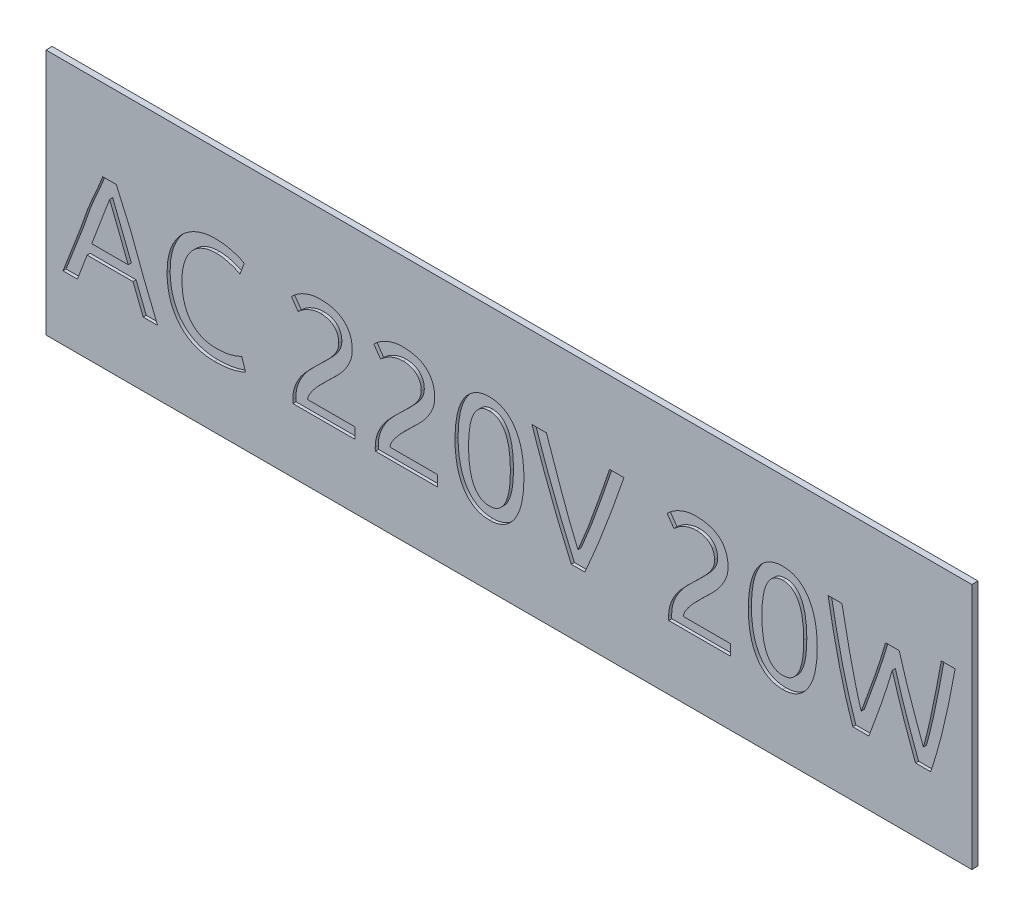
from build123d import *

# Parameters (mm, degrees)
SKETCH1_W           = 30
SKETCH1_H           = 8
BOSS_EXTRUDE1_DEPTH = 0.1
CUT_EXTRUDE1_DEPTH  = 0.1


with BuildPart() as part:
    # Sketch1 → Boss-Extrude1 (new body, symmetric)
    with BuildSketch(Plane.XY):
        Rectangle(SKETCH1_W, SKETCH1_H)
    extrude(amount=BOSS_EXTRUDE1_DEPTH, both=True)

    # Sketch2 → Cut-Extrude1 (cut)
    with BuildSketch(Plane.XY.offset(0.1)):
        with BuildLine():
            add(Edge.make_bspline(
                [(-11.85227279, -1.921252175), (-11.881209248, -1.84755212), (-11.937394401, -1.704450679), (-12.020606646, -1.494273216), (-12.10054261, -1.290409407), (-12.153603578, -1.156094189), (-12.180095068, -1.089035286)],
                knots=[0, 0, 0, 0, 0.000237531, 0.000461208, 0.000678151, 0.000894457, 0.000894457, 0.000894457, 0.000894457], degree=3))
            Line((-12.180095068, -1.089035286), (-13.667272123, -1.089035286))
            Line((-13.667272123, -1.089035286), (-13.981406623, -1.921252175))
            Line((-13.981406623, -1.921252175), (-14.449528623, -1.921252175))
            add(Edge.make_bspline(
                [(-14.449528623, -1.921252175), (-14.416767966, -1.837265115), (-14.35237101, -1.672173463), (-14.256095149, -1.429893418), (-14.165566046, -1.195825565), (-14.076612758, -0.971104345), (-13.991538842, -0.752741226), (-13.91301338, -0.538795074), (-13.836511428, -0.329944019), (-13.768048446, -0.12398361), (-13.698874096, 0.076744701), (-13.625453333, 0.271113549), (-13.54914922, 0.459554102), (-13.441064158, 0.701726294), (-13.306538256, 1.000464068), (-13.209270592, 1.243009526), (-13.160824345, 1.363814492)],
                knots=[0, 0, 0, 0, 0.000270451, 0.000531619, 0.000782119, 0.001023335, 0.001256684, 0.001485135, 0.001707035, 0.001923894, 0.002136224, 0.002343927, 0.002547145, 0.002746024, 0.003139474, 0.003529899, 0.003529899, 0.003529899, 0.003529899], degree=3))
            Line((-13.160824345, 1.363814492), (-12.723499845, 1.363814492))
            add(Edge.make_bspline(
                [(-12.723499845, 1.363814492), (-12.672336411, 1.240480212), (-12.570548355, 0.99511051), (-12.430672452, 0.693876425), (-12.319053117, 0.452074215), (-12.23866532, 0.265013959), (-12.162996772, 0.071484451), (-12.091151267, -0.128227877), (-12.01849917, -0.332570357), (-11.94087618, -0.540849081), (-11.85914948, -0.753415089), (-11.771189415, -0.970554582), (-11.679883353, -1.194918193), (-11.584777048, -1.4283051), (-11.485385721, -1.671427898), (-11.417903554, -1.836839947), (-11.383466401, -1.921252175)],
                knots=[0, 0, 0, 0, 0.000400531, 0.000796844, 0.000996219, 0.001199493, 0.00140754, 0.001619499, 0.001836195, 0.002058158, 0.002286298, 0.002519377, 0.002760975, 0.003012996, 0.003275439, 0.003548938, 0.003548938, 0.003548938, 0.003548938], degree=3))
            Line((-11.383466401, -1.921252175), (-11.85227279, -1.921252175))
        make_face()
        with BuildLine():
            add(Edge.make_bspline(
                [(-12.335451345, -0.694827286), (-12.386933947, -0.563623342), (-12.489032212, -0.303424852), (-12.642206595, 0.083084771), (-12.790703669, 0.463285439), (-12.889518593, 0.714124739), (-12.938397957, 0.838203825)],
                knots=[0, 0, 0, 0, 0.000422829, 0.000838537, 0.001247261, 0.001647341, 0.001647341, 0.001647341, 0.001647341], degree=3))
            add(Edge.make_bspline(
                [(-12.938397957, 0.838203825), (-12.985317414, 0.713388474), (-13.080227662, 0.460907804), (-13.22503166, 0.079939962), (-13.37144723, -0.30612799), (-13.468643016, -0.564994436), (-13.517390957, -0.694827286)],
                knots=[0, 0, 0, 0, 0.000400028, 0.00080919, 0.001222677, 0.001638725, 0.001638725, 0.001638725, 0.001638725], degree=3))
            Line((-13.517390957, -0.694827286), (-12.335451345, -0.694827286))
        make_face(mode=Mode.SUBTRACT)
        with BuildLine():
            add(Edge.make_bspline(
                [(-9.534932012, -2.008853952), (-9.591130066, -2.007710183), (-9.70169016, -2.00546001), (-9.863401396, -1.982662904), (-10.017768792, -1.947426107), (-10.164089719, -1.89757749), (-10.300990643, -1.832948225), (-10.428957469, -1.756000548), (-10.546384062, -1.66513231), (-10.653724916, -1.56129415), (-10.750061417, -1.444297956), (-10.834408433, -1.313844643), (-10.90764596, -1.170974839), (-10.969344718, -1.015715304), (-11.018083046, -0.848267999), (-11.051427142, -0.668506566), (-11.073433894, -0.477508953), (-11.075699134, -0.346081649), (-11.076860179, -0.278718841)],
                knots=[0, 0, 0, 0, 0.000168499, 0.000331493, 0.000488872, 0.000642971, 0.000794213, 0.00094222, 0.001090062, 0.00123865, 0.001389371, 0.0015437, 0.001703785, 0.00187027, 0.002044187, 0.00222606, 0.00241818, 0.002620191, 0.002620191, 0.002620191, 0.002620191], degree=3))
            add(Edge.make_bspline(
                [(-11.076860179, -0.278718841), (-11.075531913, -0.211352068), (-11.072939007, -0.079845536), (-11.0493811, 0.111479218), (-11.010544122, 0.291142558), (-10.956543605, 0.458723615), (-10.888313184, 0.613628463), (-10.809900728, 0.756380948), (-10.720374035, 0.886504496), (-10.619461533, 1.002918149), (-10.508886959, 1.106813042), (-10.389225276, 1.197391078), (-10.261339058, 1.275580494), (-10.124596216, 1.338659643), (-9.981863432, 1.389887553), (-9.833036749, 1.42482075), (-9.679839666, 1.44799566), (-9.575853541, 1.450267864), (-9.523297401, 1.45141627)],
                knots=[0, 0, 0, 0, 0.000202035, 0.000394392, 0.000577228, 0.000752753, 0.000921614, 0.001084276, 0.001240706, 0.001394517, 0.001545583, 0.001695056, 0.001844003, 0.001994335, 0.002146073, 0.002298124, 0.002452307, 0.002609865, 0.002609865, 0.002609865, 0.002609865], degree=3))
            add(Edge.make_bspline(
                [(-9.523297401, 1.45141627), (-9.490445274, 1.45088983), (-9.426531805, 1.449865648), (-9.333046188, 1.445743207), (-9.244768111, 1.435653957), (-9.161273582, 1.423305002), (-9.082876284, 1.409351271), (-9.010070779, 1.392336044), (-8.942296371, 1.375806428), (-8.880230227, 1.356924827), (-8.822989751, 1.338746968), (-8.771620195, 1.319452916), (-8.725125938, 1.301383096), (-8.685118623, 1.281971067), (-8.6506464, 1.264230846), (-8.621678891, 1.249354008), (-8.598828578, 1.236349683), (-8.585881026, 1.227900304), (-8.580209512, 1.224199159)],
                knots=[0, 0, 0, 0, 9.8573e-05, 0.000191773, 0.000280578, 0.000364977, 0.000444984, 0.000519365, 0.000589246, 0.000654209, 0.000713944, 0.000769375, 0.000818812, 0.000863508, 0.000902685, 0.000935134, 0.000961195, 0.000981509, 0.000981509, 0.000981509, 0.000981509], degree=3))
            Line((-8.580209512, 1.224199159), (-8.712296568, 0.85394477))
            add(Edge.make_bspline(
                [(-8.712296568, 0.85394477), (-8.729450424, 0.864113908), (-8.768764332, 0.887419954), (-8.839101326, 0.916812557), (-8.922468517, 0.95042561), (-9.018014229, 0.982619212), (-9.122900571, 1.014414597), (-9.236966499, 1.037408089), (-9.356064912, 1.05398164), (-9.43700789, 1.056133365), (-9.477443345, 1.05720827)],
                knots=[0, 0, 0, 0, 5.9762e-05, 0.000136964, 0.000228214, 0.000329504, 0.000439307, 0.000556753, 0.00067823, 0.00079949, 0.00079949, 0.00079949, 0.00079949], degree=3))
            add(Edge.make_bspline(
                [(-9.477443345, 1.05720827), (-9.519479762, 1.056251761), (-9.601864249, 1.05437716), (-9.722082705, 1.036889586), (-9.835979521, 1.008267411), (-9.942782684, 0.967670435), (-10.042995356, 0.917053172), (-10.134851155, 0.854816519), (-10.220072914, 0.783299182), (-10.29641273, 0.700778921), (-10.365361195, 0.609149597), (-10.425840162, 0.508049462), (-10.476957288, 0.397038406), (-10.520172337, 0.277380619), (-10.5531906, 0.148957005), (-10.578066098, 0.013176256), (-10.592397688, -0.130353557), (-10.594152485, -0.228498737), (-10.595050401, -0.278718841)],
                knots=[0, 0, 0, 0, 0.000126047, 0.000247031, 0.000363556, 0.000477701, 0.000589114, 0.000699587, 0.000809824, 0.000922164, 0.001036047, 0.001153301, 0.001274857, 0.001402149, 0.001534451, 0.001672181, 0.001815939, 0.001966581, 0.001966581, 0.001966581, 0.001966581], degree=3))
            add(Edge.make_bspline(
                [(-10.595050401, -0.278718841), (-10.594364859, -0.327570842), (-10.593023239, -0.423175216), (-10.579521159, -0.563065731), (-10.558650624, -0.69646275), (-10.528875833, -0.822915987), (-10.489882476, -0.941500621), (-10.442689623, -1.051926484), (-10.386405244, -1.153425703), (-10.322142542, -1.246632543), (-10.248353024, -1.329723986), (-10.16660805, -1.403828349), (-10.075368048, -1.466771654), (-9.976328783, -1.520740801), (-9.868190921, -1.563441492), (-9.751152056, -1.593203841), (-9.625602426, -1.611219736), (-9.539100307, -1.613481288), (-9.494553068, -1.614645952)],
                knots=[0, 0, 0, 0, 0.000146517, 0.000286736, 0.000421192, 0.000551336, 0.000675996, 0.000795247, 0.000911044, 0.001023628, 0.001134173, 0.001243697, 0.001353813, 0.001465894, 0.001581418, 0.001701598, 0.001827421, 0.001961019, 0.001961019, 0.001961019, 0.001961019], degree=3))
            add(Edge.make_bspline(
                [(-9.494553068, -1.614645952), (-9.443649677, -1.613951614), (-9.346470533, -1.612626059), (-9.207454804, -1.6001381), (-9.082055763, -1.580591385), (-8.97088754, -1.551182381), (-8.873601341, -1.518497448), (-8.788895061, -1.488020251), (-8.717117609, -1.459436018), (-8.674354413, -1.439608326), (-8.654807901, -1.430545341)],
                knots=[0, 0, 0, 0, 0.000152674, 0.000291468, 0.000418383, 0.00053292, 0.000635938, 0.000726218, 0.000802979, 0.000867606, 0.000867606, 0.000867606, 0.000867606], degree=3))
            Line((-8.654807901, -1.430545341), (-8.536408623, -1.80079973))
            add(Edge.make_bspline(
                [(-8.536408623, -1.80079973), (-8.542938925, -1.805277687), (-8.557557606, -1.815302004), (-8.584367584, -1.828564264), (-8.617035253, -1.844457292), (-8.672627331, -1.868340835), (-8.756790305, -1.897382374), (-8.850088635, -1.925205002), (-8.93567992, -1.945124878), (-9.007485598, -1.96035238), (-9.084892304, -1.9738574), (-9.19708314, -1.990722132), (-9.347733971, -2.005374491), (-9.471016143, -2.007665944), (-9.534932012, -2.008853952)],
                knots=[0, 0, 0, 0, 2.3728e-05, 5.3117e-05, 8.9544e-05, 0.000132769, 0.000234511, 0.000356441, 0.000424668, 0.000498089, 0.000576627, 0.000660349, 0.00083843, 0.001030158, 0.001030158, 0.001030158, 0.001030158], degree=3))
        make_face()
        with BuildLine():
            add(Edge.make_bspline(
                [(-5.076138401, 0.534335159), (-5.076984469, 0.506010066), (-5.078670018, 0.449580364), (-5.090496319, 0.365863922), (-5.110511955, 0.283586939), (-5.138994585, 0.203110094), (-5.173455769, 0.123502705), (-5.213418434, 0.044542853), (-5.258427935, -0.033807697), (-5.308587693, -0.111550492), (-5.36442748, -0.188271966), (-5.425170363, -0.265159009), (-5.492385872, -0.340751686), (-5.588331718, -0.440629094), (-5.712554085, -0.562373642), (-5.812710233, -0.659073515), (-5.862501234, -0.707146286)],
                knots=[0, 0, 0, 0, 8.4964e-05, 0.000169266, 0.000253091, 0.000338585, 0.000425035, 0.000513183, 0.000603929, 0.000695999, 0.000790596, 0.000888502, 0.00098984, 0.001093914, 0.001303944, 0.001511581, 0.001511581, 0.001511581, 0.001511581], degree=3))
            add(Edge.make_bspline(
                [(-5.862501234, -0.707146286), (-5.893077357, -0.736567754), (-5.958992895, -0.799994107), (-6.062542162, -0.899934622), (-6.171024786, -1.011127908), (-6.275565025, -1.129585839), (-6.370473162, -1.249470744), (-6.438494468, -1.348623722), (-6.481812778, -1.424342326), (-6.503825461, -1.476227725), (-6.519162448, -1.524343154), (-6.52079564, -1.555918002), (-6.521567734, -1.570845064)],
                knots=[0, 0, 0, 0, 0.000127298, 0.000274427, 0.000431725, 0.000593196, 0.000748183, 0.000890167, 0.000953582, 0.001009388, 0.001059213, 0.001103887, 0.001103887, 0.001103887, 0.001103887], degree=3))
            Line((-6.521567734, -1.570845064), (-4.988536623, -1.570845064))
            Line((-4.988536623, -1.570845064), (-4.988536623, -1.921252175))
            Line((-4.988536623, -1.921252175), (-6.99858679, -1.921252175))
            add(Edge.make_bspline(
                [(-6.99858679, -1.921252175), (-6.999875142, -1.911685165), (-7.002413836, -1.892833388), (-7.003624652, -1.86468522), (-7.003321718, -1.837757165), (-7.003359403, -1.82019089), (-7.003377512, -1.811749952)],
                knots=[0, 0, 0, 0, 2.8947e-05, 5.7041e-05, 8.4416e-05, 0.000109739, 0.000109739, 0.000109739, 0.000109739], degree=3))
            add(Edge.make_bspline(
                [(-7.003377512, -1.811749952), (-7.002435779, -1.775204048), (-7.000575057, -1.702994905), (-6.98644293, -1.596745047), (-6.964273677, -1.494156029), (-6.931399553, -1.395803893), (-6.891185596, -1.301066053), (-6.847021418, -1.208099221), (-6.796073515, -1.118494254), (-6.739879987, -1.031588089), (-6.678703172, -0.947203195), (-6.613070153, -0.865291907), (-6.543106791, -0.785441544), (-6.443508769, -0.683682054), (-6.317833509, -0.55977755), (-6.216852279, -0.46184032), (-6.16705429, -0.413543452)],
                knots=[0, 0, 0, 0, 0.000109607, 0.000216567, 0.000321012, 0.00042403, 0.000527109, 0.000629654, 0.000732624, 0.000836084, 0.00093999, 0.001045163, 0.001150879, 0.00125833, 0.001472232, 0.001680345, 0.001680345, 0.001680345, 0.001680345], degree=3))
            add(Edge.make_bspline(
                [(-6.16705429, -0.413543452), (-6.126769327, -0.375817072), (-6.047510172, -0.301591833), (-5.93274772, -0.189508401), (-5.82581015, -0.077143109), (-5.724713591, 0.032990057), (-5.637798888, 0.146423971), (-5.580104688, 0.245724525), (-5.544964462, 0.326977429), (-5.527595004, 0.389641062), (-5.515848156, 0.453820322), (-5.514717734, 0.497324906), (-5.51414729, 0.519278603)],
                knots=[0, 0, 0, 0, 0.000165577, 0.000325766, 0.000481147, 0.000630909, 0.000774084, 0.000908971, 0.000974304, 0.001039076, 0.001103659, 0.001169449, 0.001169449, 0.001169449, 0.001169449], degree=3))
            add(Edge.make_bspline(
                [(-5.51414729, 0.519278603), (-5.514566976, 0.542351605), (-5.515372446, 0.586633759), (-5.524453175, 0.650445729), (-5.539356277, 0.708770115), (-5.560049327, 0.761983345), (-5.585708751, 0.810173577), (-5.61495718, 0.854272776), (-5.64913215, 0.89363714), (-5.686726256, 0.929164346), (-5.727922644, 0.961105423), (-5.773193608, 0.987532949), (-5.821631118, 1.009635732), (-5.890736539, 1.033309678), (-5.983251284, 1.053191557), (-6.05926417, 1.055853945), (-6.097931012, 1.05720827)],
                knots=[0, 0, 0, 0, 6.9177e-05, 0.000132767, 0.000192857, 0.000249413, 0.000303601, 0.00035637, 0.000407813, 0.000459615, 0.000511357, 0.000563824, 0.000616499, 0.000670825, 0.000782773, 0.000898679, 0.000898679, 0.000898679, 0.000898679], degree=3))
            add(Edge.make_bspline(
                [(-6.097931012, 1.05720827), (-6.121228863, 1.056968636), (-6.167041753, 1.056497419), (-6.234173888, 1.048186562), (-6.298754972, 1.037438892), (-6.378092498, 1.013919689), (-6.470522871, 0.981359642), (-6.570263027, 0.934275793), (-6.657286146, 0.88419195), (-6.727436085, 0.831390759), (-6.782189037, 0.783708868), (-6.815343368, 0.756696022), (-6.829542734, 0.745126936)],
                knots=[0, 0, 0, 0, 6.9838e-05, 0.000137329, 0.000202705, 0.000265973, 0.000385255, 0.000496392, 0.000596397, 0.000685916, 0.000759261, 0.000814204, 0.000814204, 0.000814204, 0.000814204], degree=3))
            Line((-6.829542734, 0.745126936), (-7.047178401, 1.058577048))
            add(Edge.make_bspline(
                [(-7.047178401, 1.058577048), (-7.039274831, 1.066871092), (-7.021904289, 1.085099824), (-6.992041451, 1.112556141), (-6.956813408, 1.142813018), (-6.901599285, 1.18798956), (-6.820955122, 1.24531385), (-6.709554671, 1.308583114), (-6.582271628, 1.365057123), (-6.466113676, 1.404093191), (-6.366519119, 1.428396839), (-6.287720227, 1.442401568), (-6.205747059, 1.449677532), (-6.150185285, 1.450829506), (-6.121884623, 1.45141627)],
                knots=[0, 0, 0, 0, 3.4363e-05, 7.5523e-05, 0.000121622, 0.000173676, 0.000289513, 0.000417949, 0.000557344, 0.000706676, 0.000784858, 0.000864744, 0.000946534, 0.001031442, 0.001031442, 0.001031442, 0.001031442], degree=3))
            add(Edge.make_bspline(
                [(-6.121884623, 1.45141627), (-6.079646094, 1.45094402), (-5.997733075, 1.450028187), (-5.879128489, 1.437724311), (-5.768175867, 1.420008038), (-5.665681313, 1.393181483), (-5.571062511, 1.359853146), (-5.484607489, 1.318613854), (-5.406495116, 1.269439952), (-5.336733516, 1.212604219), (-5.274781693, 1.14977835), (-5.221839944, 1.079720036), (-5.176358934, 1.004143365), (-5.139110417, 0.922245572), (-5.111307992, 0.833630015), (-5.090901499, 0.739271501), (-5.078331265, 0.638698852), (-5.076882159, 0.569732398), (-5.076138401, 0.534335159)],
                knots=[0, 0, 0, 0, 0.000126658, 0.000245628, 0.000357353, 0.000463424, 0.000563002, 0.000657896, 0.000750174, 0.000839211, 0.000927292, 0.001014212, 0.001102006, 0.001191442, 0.001283428, 0.001380079, 0.001480757, 0.001586916, 0.001586916, 0.001586916, 0.001586916], degree=3))
        make_face()
        with BuildLine():
            add(Edge.make_bspline(
                [(-2.404284179, 0.534335159), (-2.405130246, 0.506010066), (-2.406815796, 0.449580364), (-2.418642097, 0.365863922), (-2.438657733, 0.283586939), (-2.467140363, 0.203110094), (-2.501601546, 0.123502705), (-2.541564211, 0.044542853), (-2.586573713, -0.033807697), (-2.63673347, -0.111550492), (-2.692573258, -0.188271966), (-2.753316141, -0.265159009), (-2.82053165, -0.340751686), (-2.916477496, -0.440629094), (-3.040699862, -0.562373642), (-3.140856011, -0.659073515), (-3.190647012, -0.707146286)],
                knots=[0, 0, 0, 0, 8.4964e-05, 0.000169266, 0.000253091, 0.000338585, 0.000425035, 0.000513183, 0.000603929, 0.000695999, 0.000790596, 0.000888502, 0.00098984, 0.001093914, 0.001303944, 0.001511581, 0.001511581, 0.001511581, 0.001511581], degree=3))
            add(Edge.make_bspline(
                [(-3.190647012, -0.707146286), (-3.221223135, -0.736567754), (-3.287138673, -0.799994107), (-3.39068794, -0.899934622), (-3.499170563, -1.011127908), (-3.603710803, -1.129585839), (-3.69861894, -1.249470744), (-3.766640246, -1.348623722), (-3.809958555, -1.424342326), (-3.831971239, -1.476227725), (-3.847308226, -1.524343154), (-3.848941418, -1.555918002), (-3.849713512, -1.570845064)],
                knots=[0, 0, 0, 0, 0.000127298, 0.000274427, 0.000431725, 0.000593196, 0.000748183, 0.000890167, 0.000953582, 0.001009388, 0.001059213, 0.001103887, 0.001103887, 0.001103887, 0.001103887], degree=3))
            Line((-3.849713512, -1.570845064), (-2.316682401, -1.570845064))
            Line((-2.316682401, -1.570845064), (-2.316682401, -1.921252175))
            Line((-2.316682401, -1.921252175), (-4.326732568, -1.921252175))
            add(Edge.make_bspline(
                [(-4.326732568, -1.921252175), (-4.328020919, -1.911685165), (-4.330559614, -1.892833388), (-4.33177043, -1.86468522), (-4.331467495, -1.837757165), (-4.331505181, -1.82019089), (-4.33152329, -1.811749952)],
                knots=[0, 0, 0, 0, 2.8947e-05, 5.7041e-05, 8.4416e-05, 0.000109739, 0.000109739, 0.000109739, 0.000109739], degree=3))
            add(Edge.make_bspline(
                [(-4.33152329, -1.811749952), (-4.330581557, -1.775204048), (-4.328720835, -1.702994905), (-4.314588708, -1.596745047), (-4.292419454, -1.494156029), (-4.25954533, -1.395803893), (-4.219331374, -1.301066053), (-4.175167196, -1.208099221), (-4.124219293, -1.118494254), (-4.068025765, -1.031588089), (-4.00684895, -0.947203195), (-3.941215931, -0.865291907), (-3.871252569, -0.785441544), (-3.771654547, -0.683682054), (-3.645979286, -0.55977755), (-3.544998056, -0.46184032), (-3.495200068, -0.413543452)],
                knots=[0, 0, 0, 0, 0.000109607, 0.000216567, 0.000321012, 0.00042403, 0.000527109, 0.000629654, 0.000732624, 0.000836084, 0.00093999, 0.001045163, 0.001150879, 0.00125833, 0.001472232, 0.001680345, 0.001680345, 0.001680345, 0.001680345], degree=3))
            add(Edge.make_bspline(
                [(-3.495200068, -0.413543452), (-3.454915105, -0.375817072), (-3.37565595, -0.301591833), (-3.260893498, -0.189508401), (-3.153955928, -0.077143109), (-3.052859369, 0.032990057), (-2.965944666, 0.146423971), (-2.908250466, 0.245724525), (-2.87311024, 0.326977429), (-2.855740782, 0.389641062), (-2.843993934, 0.453820322), (-2.842863512, 0.497324906), (-2.842293068, 0.519278603)],
                knots=[0, 0, 0, 0, 0.000165577, 0.000325766, 0.000481147, 0.000630909, 0.000774084, 0.000908971, 0.000974304, 0.001039076, 0.001103659, 0.001169449, 0.001169449, 0.001169449, 0.001169449], degree=3))
            add(Edge.make_bspline(
                [(-2.842293068, 0.519278603), (-2.842712754, 0.542351605), (-2.843518223, 0.586633759), (-2.852598953, 0.650445729), (-2.867502054, 0.708770115), (-2.888195105, 0.761983345), (-2.913854529, 0.810173577), (-2.943102958, 0.854272776), (-2.977277928, 0.89363714), (-3.014872034, 0.929164346), (-3.056068422, 0.961105423), (-3.101339386, 0.987532949), (-3.149776896, 1.009635732), (-3.218882317, 1.033309678), (-3.311397062, 1.053191557), (-3.387409947, 1.055853945), (-3.42607679, 1.05720827)],
                knots=[0, 0, 0, 0, 6.9177e-05, 0.000132767, 0.000192857, 0.000249413, 0.000303601, 0.00035637, 0.000407813, 0.000459615, 0.000511357, 0.000563824, 0.000616499, 0.000670825, 0.000782773, 0.000898679, 0.000898679, 0.000898679, 0.000898679], degree=3))
            add(Edge.make_bspline(
                [(-3.42607679, 1.05720827), (-3.44937464, 1.056968636), (-3.495187531, 1.056497419), (-3.562319666, 1.048186562), (-3.626900749, 1.037438892), (-3.706238276, 1.013919689), (-3.798668649, 0.981359642), (-3.898408805, 0.934275793), (-3.985431923, 0.88419195), (-4.055581863, 0.831390759), (-4.110334815, 0.783708868), (-4.143489146, 0.756696022), (-4.157688512, 0.745126936)],
                knots=[0, 0, 0, 0, 6.9838e-05, 0.000137329, 0.000202705, 0.000265973, 0.000385255, 0.000496392, 0.000596397, 0.000685916, 0.000759261, 0.000814204, 0.000814204, 0.000814204, 0.000814204], degree=3))
            Line((-4.157688512, 0.745126936), (-4.375324179, 1.058577048))
            add(Edge.make_bspline(
                [(-4.375324179, 1.058577048), (-4.367420609, 1.066871092), (-4.350050067, 1.085099824), (-4.320187229, 1.112556141), (-4.284959186, 1.142813018), (-4.229745063, 1.18798956), (-4.1491009, 1.24531385), (-4.037700448, 1.308583114), (-3.910417406, 1.365057123), (-3.794259454, 1.404093191), (-3.694664897, 1.428396839), (-3.615866005, 1.442401568), (-3.533892836, 1.449677532), (-3.478331062, 1.450829506), (-3.450030401, 1.45141627)],
                knots=[0, 0, 0, 0, 3.4363e-05, 7.5523e-05, 0.000121622, 0.000173676, 0.000289513, 0.000417949, 0.000557344, 0.000706676, 0.000784858, 0.000864744, 0.000946534, 0.001031442, 0.001031442, 0.001031442, 0.001031442], degree=3))
            add(Edge.make_bspline(
                [(-3.450030401, 1.45141627), (-3.407791872, 1.45094402), (-3.325878853, 1.450028187), (-3.207274266, 1.437724311), (-3.096321644, 1.420008038), (-2.993827091, 1.393181483), (-2.899208289, 1.359853146), (-2.812753267, 1.318613854), (-2.734640894, 1.269439952), (-2.664879294, 1.212604219), (-2.60292747, 1.14977835), (-2.549985722, 1.079720036), (-2.504504712, 1.004143365), (-2.467256195, 0.922245572), (-2.43945377, 0.833630015), (-2.419047277, 0.739271501), (-2.406477043, 0.638698852), (-2.405027937, 0.569732398), (-2.404284179, 0.534335159)],
                knots=[0, 0, 0, 0, 0.000126658, 0.000245628, 0.000357353, 0.000463424, 0.000563002, 0.000657896, 0.000750174, 0.000839211, 0.000927292, 0.001014212, 0.001102006, 0.001191442, 0.001283428, 0.001380079, 0.001480757, 0.001586916, 0.001586916, 0.001586916, 0.001586916], degree=3))
        make_face()
        with BuildLine():
            add(Edge.make_bspline(
                [(-1.747270845, -0.278718841), (-1.746333008, -0.211398755), (-1.744509344, -0.08049198), (-1.730959487, 0.109875021), (-1.707780553, 0.28810238), (-1.676087861, 0.454490003), (-1.634233096, 0.608840319), (-1.584149834, 0.751820445), (-1.523599789, 0.882531481), (-1.454730507, 1.001249511), (-1.37757365, 1.107158766), (-1.292129205, 1.199131105), (-1.199195665, 1.277011426), (-1.099372368, 1.341383534), (-0.992281872, 1.391171376), (-0.878021036, 1.425940355), (-0.756666267, 1.447936198), (-0.673105531, 1.450238302), (-0.630348179, 1.45141627)],
                knots=[0, 0, 0, 0, 0.000201952, 0.000392703, 0.00057216, 0.000740876, 0.000900423, 0.001051516, 0.00119482, 0.00133192, 0.001462645, 0.001587093, 0.001707581, 0.001825474, 0.001942441, 0.002060636, 0.002182943, 0.002311107, 0.002311107, 0.002311107, 0.002311107], degree=3))
            add(Edge.make_bspline(
                [(-0.630348179, 1.45141627), (-0.587590638, 1.450238527), (-0.504029533, 1.447936863), (-0.382677403, 1.425937873), (-0.268406993, 1.391180308), (-0.161351764, 1.341350422), (-0.0615425, 1.277232), (0.030763885, 1.198879618), (0.1162257, 1.107195198), (0.193328148, 1.001234659), (0.262273967, 0.882553204), (0.322590466, 0.751674317), (0.373751474, 0.608998978), (0.415323192, 0.454465471), (0.447104211, 0.288109568), (0.470257279, 0.10987292), (0.483814589, -0.080491405), (0.485637195, -0.21139856), (0.486574488, -0.278718841)],
                knots=[0, 0, 0, 0, 0.000128164, 0.00025047, 0.000368666, 0.000485632, 0.000603526, 0.000723489, 0.000847937, 0.000978663, 0.001115763, 0.001259066, 0.001410391, 0.001569937, 0.001738654, 0.00191811, 0.002108862, 0.002310813, 0.002310813, 0.002310813, 0.002310813], degree=3))
            add(Edge.make_bspline(
                [(0.486574488, -0.278718841), (0.485637773, -0.346039279), (0.48381629, -0.476946735), (0.470251071, -0.667308933), (0.447125448, -0.845552964), (0.415209232, -1.012100085), (0.373879953, -1.166928099), (0.32257693, -1.309792462), (0.262278079, -1.440677403), (0.193324559, -1.559352193), (0.116235489, -1.665332313), (0.030730432, -1.756949437), (-0.061329866, -1.835460346), (-0.161573128, -1.898668337), (-0.268377347, -1.948664373), (-0.38268564, -1.983362669), (-0.504027328, -2.005377996), (-0.587589891, -2.007677377), (-0.630348179, -2.008853952)],
                knots=[0, 0, 0, 0, 0.000201952, 0.000392703, 0.00057216, 0.000740876, 0.000901083, 0.001052407, 0.001195711, 0.001332811, 0.001463537, 0.001587985, 0.001707948, 0.001825474, 0.00194244, 0.002060636, 0.002182942, 0.002311106, 0.002311106, 0.002311106, 0.002311106], degree=3))
            add(Edge.make_bspline(
                [(-0.630348179, -2.008853952), (-0.673106277, -2.007677152), (-0.756668471, -2.005377329), (-0.878012804, -1.983365158), (-0.992311502, -1.948655415), (-1.099151029, -1.898701503), (-1.199409223, -1.835241085), (-1.292095734, -1.757200881), (-1.377583429, -1.665295867), (-1.454726916, -1.559367046), (-1.523603927, -1.440655689), (-1.5841362, -1.309938554), (-1.634360389, -1.166769023), (-1.675974005, -1.012124655), (-1.707801794, -0.845545777), (-1.730953278, -0.667311034), (-1.744511045, -0.47694616), (-1.746333586, -0.346039083), (-1.747270845, -0.278718841)],
                knots=[0, 0, 0, 0, 0.000128164, 0.00025047, 0.000368666, 0.000485632, 0.000603158, 0.000723645, 0.000848093, 0.000978818, 0.001115918, 0.001259222, 0.001410316, 0.001570523, 0.00173924, 0.001918696, 0.002109448, 0.002311399, 0.002311399, 0.002311399, 0.002311399], degree=3))
        make_face()
        with BuildLine():
            add(Edge.make_bspline(
                [(0.048565599, -0.278718841), (0.048179063, -0.233998356), (0.047415478, -0.14565497), (0.041127453, -0.01508994), (0.030901228, 0.111825958), (0.016757988, 0.234472985), (-0.001705668, 0.351883739), (-0.02717472, 0.462236088), (-0.057679779, 0.565021904), (-0.093853827, 0.65994889), (-0.135818547, 0.746641961), (-0.185508496, 0.824014552), (-0.241732022, 0.892370855), (-0.304942769, 0.951048762), (-0.374935791, 0.999251275), (-0.453374616, 1.033335299), (-0.539460255, 1.053414156), (-0.599441554, 1.055918074), (-0.630348179, 1.05720827)],
                knots=[0, 0, 0, 0, 0.000134156, 0.000265019, 0.000392047, 0.000516072, 0.000635337, 0.000748396, 0.000855574, 0.000956746, 0.001052853, 0.001143977, 0.001231955, 0.001317678, 0.001401958, 0.001485625, 0.001572779, 0.001665425, 0.001665425, 0.001665425, 0.001665425], degree=3))
            add(Edge.make_bspline(
                [(-0.630348179, 1.05720827), (-0.661258225, 1.055927041), (-0.721246163, 1.053440527), (-0.807489791, 1.033190584), (-0.886274234, 0.99941645), (-0.95640911, 0.95125049), (-1.018958839, 0.892123767), (-1.075219413, 0.824047714), (-1.124868725, 0.746632411), (-1.16684516, 0.659951654), (-1.203015813, 0.565021099), (-1.23352186, 0.462236322), (-1.258990625, 0.351883671), (-1.277454364, 0.234473004), (-1.291597581, 0.111825952), (-1.301823812, -0.015089939), (-1.308111835, -0.14565497), (-1.308875421, -0.233998356), (-1.309261957, -0.278718841)],
                knots=[0, 0, 0, 0, 9.2646e-05, 0.0001798, 0.000264094, 0.000348374, 0.000433596, 0.000521574, 0.000612698, 0.000708805, 0.000809977, 0.000917155, 0.001030214, 0.001149478, 0.001273504, 0.001400531, 0.001531395, 0.001665551, 0.001665551, 0.001665551, 0.001665551], degree=3))
            add(Edge.make_bspline(
                [(-1.309261957, -0.278718841), (-1.308874763, -0.323439265), (-1.308109879, -0.411782528), (-1.301831323, -0.542348451), (-1.291552321, -0.669486997), (-1.277495971, -0.792369768), (-1.259082599, -0.909799822), (-1.233412666, -1.01987659), (-1.203027134, -1.122461417), (-1.166842361, -1.217388685), (-1.124869417, -1.304070255), (-1.075219238, -1.381485356), (-1.018958884, -1.44956146), (-0.956409099, -1.50868817), (-0.886274237, -1.556854134), (-0.80748979, -1.590628266), (-0.721246163, -1.61087821), (-0.661258225, -1.613364724), (-0.630348179, -1.614645952)],
                knots=[0, 0, 0, 0, 0.000134156, 0.000265019, 0.000392047, 0.000516752, 0.000636017, 0.000748408, 0.000855587, 0.000956759, 0.001052866, 0.00114399, 0.001231968, 0.00131719, 0.00140147, 0.001485764, 0.001572918, 0.001665564, 0.001665564, 0.001665564, 0.001665564], degree=3))
            add(Edge.make_bspline(
                [(-0.630348179, -1.614645952), (-0.599441554, -1.613355756), (-0.539460255, -1.610851839), (-0.453374617, -1.590772982), (-0.374935788, -1.556688959), (-0.304942781, -1.508486442), (-0.241731977, -1.449808548), (-0.185508671, -1.381452195), (-0.135817854, -1.304079805), (-0.093856627, -1.21738592), (-0.057668458, -1.122462223), (-0.027283913, -1.019876357), (-0.001613694, -0.90979989), (0.016799594, -0.792369749), (0.030855968, -0.669487002), (0.041134964, -0.542348449), (0.047413521, -0.411782529), (0.048178405, -0.323439265), (0.048565599, -0.278718841)],
                knots=[0, 0, 0, 0, 9.2646e-05, 0.0001798, 0.000263466, 0.000347746, 0.00043347, 0.000521448, 0.000612572, 0.000708679, 0.000809851, 0.000917029, 0.001029421, 0.001148685, 0.001273391, 0.001400418, 0.001531282, 0.001665437, 0.001665437, 0.001665437, 0.001665437], degree=3))
        make_face(mode=Mode.SUBTRACT)
        with BuildLine():
            add(Edge.make_bspline(
                [(3.727840266, 1.363814492), (3.698725207, 1.278464738), (3.641611524, 1.111038016), (3.555996304, 0.864823385), (3.471724184, 0.62867343), (3.390389115, 0.401249122), (3.309416142, 0.182116178), (3.231512767, -0.031427295), (3.15221823, -0.238636615), (3.05043703, -0.505379283), (2.924053565, -0.826933857), (2.77020801, -1.200558009), (2.616250544, -1.563986387), (2.510425111, -1.802316863), (2.457614488, -1.921252175)],
                knots=[0, 0, 0, 0, 0.000270537, 0.0005307, 0.000782016, 0.001022744, 0.001255286, 0.001482858, 0.001704661, 0.001920861, 0.002339367, 0.002741109, 0.003133011, 0.003523403, 0.003523403, 0.003523403, 0.003523403], degree=3))
            Line((2.457614488, -1.921252175), (2.019605599, -1.921252175))
            add(Edge.make_bspline(
                [(2.019605599, -1.921252175), (1.967356975, -1.802270539), (1.862583727, -1.563678758), (1.708260102, -1.200610237), (1.554636082, -0.826709404), (1.427531141, -0.505096868), (1.323177714, -0.238986623), (1.244940975, -0.030945347), (1.163939818, 0.181778411), (1.082753915, 0.40117659), (1.001288642, 0.628556308), (0.917753479, 0.864730805), (0.833480877, 1.110940733), (0.777769871, 1.278451727), (0.749379821, 1.363814492)],
                knots=[0, 0, 0, 0, 0.000389842, 0.000781744, 0.001183485, 0.001602495, 0.001819188, 0.002040991, 0.002269282, 0.00250206, 0.002742788, 0.002993875, 0.003253592, 0.003523471, 0.003523471, 0.003523471, 0.003523471], degree=3))
            Line((0.749379821, 1.363814492), (1.215448655, 1.363814492))
            add(Edge.make_bspline(
                [(1.215448655, 1.363814492), (1.258555242, 1.238796134), (1.34392242, 0.991212986), (1.470996917, 0.623230579), (1.597835624, 0.262942874), (1.722398143, -0.090237438), (1.847899794, -0.434072528), (1.975304963, -0.767682558), (2.104126704, -1.090761408), (2.193732742, -1.301358374), (2.237925655, -1.405222952)],
                knots=[0, 0, 0, 0, 0.000396724, 0.000785663, 0.001167913, 0.001542609, 0.001909166, 0.002265946, 0.002613912, 0.002952529, 0.002952529, 0.002952529, 0.002952529], degree=3))
            add(Edge.make_bspline(
                [(2.237925655, -1.405222952), (2.282359745, -1.302050198), (2.372541043, -1.092655725), (2.502179078, -0.770759191), (2.630105926, -0.437307951), (2.756300018, -0.092787906), (2.881401161, 0.261278306), (3.008368419, 0.622436385), (3.134631008, 0.990919728), (3.219143227, 1.238788683), (3.261771432, 1.363814492)],
                knots=[0, 0, 0, 0, 0.000336993, 0.000683945, 0.001040969, 0.001408405, 0.001784619, 0.002167516, 0.002556878, 0.002953158, 0.002953158, 0.002953158, 0.002953158], degree=3))
            Line((3.261771432, 1.363814492), (3.727840266, 1.363814492))
        make_face()
        with BuildLine():
            add(Edge.make_bspline(
                [(7.10050871, 0.534335159), (7.099662643, 0.506010066), (7.097977093, 0.449580364), (7.086150792, 0.365863922), (7.066135156, 0.283586939), (7.037652526, 0.203110094), (7.003191343, 0.123502705), (6.963228678, 0.044542853), (6.918219176, -0.033807697), (6.868059418, -0.111550492), (6.812219631, -0.188271966), (6.751476748, -0.265159009), (6.684261239, -0.340751686), (6.588315393, -0.440629094), (6.464093026, -0.562373642), (6.363936878, -0.659073515), (6.314145877, -0.707146286)],
                knots=[0, 0, 0, 0, 8.4964e-05, 0.000169266, 0.000253091, 0.000338585, 0.000425035, 0.000513183, 0.000603929, 0.000695999, 0.000790596, 0.000888502, 0.00098984, 0.001093914, 0.001303944, 0.001511581, 0.001511581, 0.001511581, 0.001511581], degree=3))
            add(Edge.make_bspline(
                [(6.314145877, -0.707146286), (6.283569754, -0.736567754), (6.217654216, -0.799994107), (6.114104949, -0.899934622), (6.005622325, -1.011127908), (5.901082086, -1.129585839), (5.806173949, -1.249470744), (5.738152643, -1.348623722), (5.694834334, -1.424342326), (5.67282165, -1.476227725), (5.657484663, -1.524343154), (5.655851471, -1.555918002), (5.655079377, -1.570845064)],
                knots=[0, 0, 0, 0, 0.000127298, 0.000274427, 0.000431725, 0.000593196, 0.000748183, 0.000890167, 0.000953582, 0.001009388, 0.001059213, 0.001103887, 0.001103887, 0.001103887, 0.001103887], degree=3))
            Line((5.655079377, -1.570845064), (7.188110488, -1.570845064))
            Line((7.188110488, -1.570845064), (7.188110488, -1.921252175))
            Line((7.188110488, -1.921252175), (5.178060321, -1.921252175))
            add(Edge.make_bspline(
                [(5.178060321, -1.921252175), (5.176771969, -1.911685165), (5.174233275, -1.892833388), (5.173022459, -1.86468522), (5.173325393, -1.837757165), (5.173287708, -1.82019089), (5.173269599, -1.811749952)],
                knots=[0, 0, 0, 0, 2.8947e-05, 5.7041e-05, 8.4416e-05, 0.000109739, 0.000109739, 0.000109739, 0.000109739], degree=3))
            add(Edge.make_bspline(
                [(5.173269599, -1.811749952), (5.174211332, -1.775204048), (5.176072054, -1.702994905), (5.190204181, -1.596745047), (5.212373435, -1.494156029), (5.245247558, -1.395803893), (5.285461515, -1.301066053), (5.329625693, -1.208099221), (5.380573596, -1.118494254), (5.436767124, -1.031588089), (5.497943939, -0.947203195), (5.563576958, -0.865291907), (5.63354032, -0.785441544), (5.733138342, -0.683682054), (5.858813603, -0.55977755), (5.959794833, -0.46184032), (6.009592821, -0.413543452)],
                knots=[0, 0, 0, 0, 0.000109607, 0.000216567, 0.000321012, 0.00042403, 0.000527109, 0.000629654, 0.000732624, 0.000836084, 0.00093999, 0.001045163, 0.001150879, 0.00125833, 0.001472232, 0.001680345, 0.001680345, 0.001680345, 0.001680345], degree=3))
            add(Edge.make_bspline(
                [(6.009592821, -0.413543452), (6.049877784, -0.375817072), (6.129136939, -0.301591833), (6.243899391, -0.189508401), (6.350836961, -0.077143109), (6.45193352, 0.032990057), (6.538848223, 0.146423971), (6.596542423, 0.245724525), (6.631682649, 0.326977429), (6.649052107, 0.389641062), (6.660798955, 0.453820322), (6.661929377, 0.497324906), (6.662499821, 0.519278603)],
                knots=[0, 0, 0, 0, 0.000165577, 0.000325766, 0.000481147, 0.000630909, 0.000774084, 0.000908971, 0.000974304, 0.001039076, 0.001103659, 0.001169449, 0.001169449, 0.001169449, 0.001169449], degree=3))
            add(Edge.make_bspline(
                [(6.662499821, 0.519278603), (6.662080135, 0.542351605), (6.661274665, 0.586633759), (6.652193936, 0.650445729), (6.637290835, 0.708770115), (6.616597784, 0.761983345), (6.59093836, 0.810173577), (6.561689931, 0.854272776), (6.527514961, 0.89363714), (6.489920855, 0.929164346), (6.448724467, 0.961105423), (6.403453503, 0.987532949), (6.355015993, 1.009635732), (6.285910572, 1.033309678), (6.193395827, 1.053191557), (6.117382942, 1.055853945), (6.078716099, 1.05720827)],
                knots=[0, 0, 0, 0, 6.9177e-05, 0.000132767, 0.000192857, 0.000249413, 0.000303601, 0.00035637, 0.000407813, 0.000459615, 0.000511357, 0.000563824, 0.000616499, 0.000670825, 0.000782773, 0.000898679, 0.000898679, 0.000898679, 0.000898679], degree=3))
            add(Edge.make_bspline(
                [(6.078716099, 1.05720827), (6.055418248, 1.056968636), (6.009605358, 1.056497419), (5.942473223, 1.048186562), (5.877892139, 1.037438892), (5.798554613, 1.013919689), (5.70612424, 0.981359642), (5.606384084, 0.934275793), (5.519360966, 0.88419195), (5.449211026, 0.831390759), (5.394458074, 0.783708868), (5.361303743, 0.756696022), (5.347104377, 0.745126936)],
                knots=[0, 0, 0, 0, 6.9838e-05, 0.000137329, 0.000202705, 0.000265973, 0.000385255, 0.000496392, 0.000596397, 0.000685916, 0.000759261, 0.000814204, 0.000814204, 0.000814204, 0.000814204], degree=3))
            Line((5.347104377, 0.745126936), (5.12946871, 1.058577048))
            add(Edge.make_bspline(
                [(5.12946871, 1.058577048), (5.13737228, 1.066871092), (5.154742822, 1.085099824), (5.18460566, 1.112556141), (5.219833703, 1.142813018), (5.275047826, 1.18798956), (5.355691989, 1.24531385), (5.467092441, 1.308583114), (5.594375483, 1.365057123), (5.710533435, 1.404093191), (5.810127992, 1.428396839), (5.888926884, 1.442401568), (5.970900053, 1.449677532), (6.026461826, 1.450829506), (6.054762488, 1.45141627)],
                knots=[0, 0, 0, 0, 3.4363e-05, 7.5523e-05, 0.000121622, 0.000173676, 0.000289513, 0.000417949, 0.000557344, 0.000706676, 0.000784858, 0.000864744, 0.000946534, 0.001031442, 0.001031442, 0.001031442, 0.001031442], degree=3))
            add(Edge.make_bspline(
                [(6.054762488, 1.45141627), (6.097001017, 1.45094402), (6.178914036, 1.450028187), (6.297518623, 1.437724311), (6.408471244, 1.420008038), (6.510965798, 1.393181483), (6.6055846, 1.359853146), (6.692039622, 1.318613854), (6.770151995, 1.269439952), (6.839913595, 1.212604219), (6.901865419, 1.14977835), (6.954807167, 1.079720036), (7.000288177, 1.004143365), (7.037536694, 0.922245572), (7.065339119, 0.833630015), (7.085745612, 0.739271501), (7.098315846, 0.638698852), (7.099764952, 0.569732398), (7.10050871, 0.534335159)],
                knots=[0, 0, 0, 0, 0.000126658, 0.000245628, 0.000357353, 0.000463424, 0.000563002, 0.000657896, 0.000750174, 0.000839211, 0.000927292, 0.001014212, 0.001102006, 0.001191442, 0.001283428, 0.001380079, 0.001480757, 0.001586916, 0.001586916, 0.001586916, 0.001586916], degree=3))
        make_face()
        with BuildLine():
            add(Edge.make_bspline(
                [(7.757522043, -0.278718841), (7.75845988, -0.211398755), (7.760283544, -0.08049198), (7.773833402, 0.109875021), (7.797012336, 0.28810238), (7.828705028, 0.454490003), (7.870559793, 0.608840319), (7.920643055, 0.751820445), (7.9811931, 0.882531481), (8.050062381, 1.001249511), (8.127219239, 1.107158766), (8.212663684, 1.199131105), (8.305597224, 1.277011426), (8.405420521, 1.341383534), (8.512511016, 1.391171376), (8.626771853, 1.425940355), (8.748126622, 1.447936198), (8.831687358, 1.450238302), (8.87444471, 1.45141627)],
                knots=[0, 0, 0, 0, 0.000201952, 0.000392703, 0.00057216, 0.000740876, 0.000900423, 0.001051516, 0.00119482, 0.00133192, 0.001462645, 0.001587093, 0.001707581, 0.001825474, 0.001942441, 0.002060636, 0.002182943, 0.002311107, 0.002311107, 0.002311107, 0.002311107], degree=3))
            add(Edge.make_bspline(
                [(8.87444471, 1.45141627), (8.917202251, 1.450238527), (9.000763356, 1.447936863), (9.122115486, 1.425937873), (9.236385896, 1.391180308), (9.343441125, 1.341350422), (9.443250389, 1.277232), (9.535556774, 1.198879618), (9.621018588, 1.107195198), (9.698121037, 1.001234659), (9.767066856, 0.882553204), (9.827383354, 0.751674317), (9.878544363, 0.608998978), (9.920116081, 0.454465471), (9.9518971, 0.288109568), (9.975050168, 0.10987292), (9.988607478, -0.080491405), (9.990430084, -0.21139856), (9.991367377, -0.278718841)],
                knots=[0, 0, 0, 0, 0.000128164, 0.00025047, 0.000368666, 0.000485632, 0.000603526, 0.000723489, 0.000847937, 0.000978663, 0.001115763, 0.001259066, 0.001410391, 0.001569937, 0.001738654, 0.00191811, 0.002108862, 0.002310813, 0.002310813, 0.002310813, 0.002310813], degree=3))
            add(Edge.make_bspline(
                [(9.991367377, -0.278718841), (9.990430661, -0.346039279), (9.988609179, -0.476946735), (9.97504396, -0.667308933), (9.951918337, -0.845552964), (9.920002121, -1.012100085), (9.878672842, -1.166928099), (9.827369819, -1.309792462), (9.767070968, -1.440677403), (9.698117448, -1.559352193), (9.621028378, -1.665332313), (9.535523321, -1.756949437), (9.443463023, -1.835460346), (9.343219761, -1.898668337), (9.236415542, -1.948664373), (9.122107249, -1.983362669), (9.000765561, -2.005377996), (8.917202998, -2.007677377), (8.87444471, -2.008853952)],
                knots=[0, 0, 0, 0, 0.000201952, 0.000392703, 0.00057216, 0.000740876, 0.000901083, 0.001052407, 0.001195711, 0.001332811, 0.001463537, 0.001587985, 0.001707948, 0.001825474, 0.00194244, 0.002060636, 0.002182942, 0.002311106, 0.002311106, 0.002311106, 0.002311106], degree=3))
            add(Edge.make_bspline(
                [(8.87444471, -2.008853952), (8.831686611, -2.007677152), (8.748124418, -2.005377329), (8.626780085, -1.983365158), (8.512481387, -1.948655415), (8.40564186, -1.898701503), (8.305383666, -1.835241085), (8.212697155, -1.757200881), (8.12720946, -1.665295867), (8.050065973, -1.559367046), (7.981188962, -1.440655689), (7.920656689, -1.309938554), (7.8704325, -1.166769023), (7.828818884, -1.012124655), (7.796991095, -0.845545777), (7.773839611, -0.667311034), (7.760281844, -0.47694616), (7.758459303, -0.346039083), (7.757522043, -0.278718841)],
                knots=[0, 0, 0, 0, 0.000128164, 0.00025047, 0.000368666, 0.000485632, 0.000603158, 0.000723645, 0.000848093, 0.000978818, 0.001115918, 0.001259222, 0.001410316, 0.001570523, 0.00173924, 0.001918696, 0.002109448, 0.002311399, 0.002311399, 0.002311399, 0.002311399], degree=3))
        make_face()
        with BuildLine():
            add(Edge.make_bspline(
                [(9.553358488, -0.278718841), (9.552971952, -0.233998356), (9.552208367, -0.14565497), (9.545920342, -0.01508994), (9.535694117, 0.111825958), (9.521550877, 0.234472985), (9.503087221, 0.351883739), (9.477618168, 0.462236088), (9.44711311, 0.565021904), (9.410939062, 0.65994889), (9.368974342, 0.746641961), (9.319284393, 0.824014552), (9.263060867, 0.892370855), (9.19985012, 0.951048762), (9.129857098, 0.999251275), (9.051418273, 1.033335299), (8.965332634, 1.053414156), (8.905351335, 1.055918074), (8.87444471, 1.05720827)],
                knots=[0, 0, 0, 0, 0.000134156, 0.000265019, 0.000392047, 0.000516072, 0.000635337, 0.000748396, 0.000855574, 0.000956746, 0.001052853, 0.001143977, 0.001231955, 0.001317678, 0.001401958, 0.001485625, 0.001572779, 0.001665425, 0.001665425, 0.001665425, 0.001665425], degree=3))
            add(Edge.make_bspline(
                [(8.87444471, 1.05720827), (8.843534664, 1.055927041), (8.783546726, 1.053440527), (8.697303098, 1.033190584), (8.618518655, 0.99941645), (8.548383778, 0.95125049), (8.48583405, 0.892123767), (8.429573476, 0.824047714), (8.379924164, 0.746632411), (8.337947728, 0.659951654), (8.301777076, 0.565021099), (8.271271029, 0.462236322), (8.245802264, 0.351883671), (8.227338524, 0.234473004), (8.213195308, 0.111825952), (8.202969077, -0.015089939), (8.196681054, -0.14565497), (8.195917468, -0.233998356), (8.195530932, -0.278718841)],
                knots=[0, 0, 0, 0, 9.2646e-05, 0.0001798, 0.000264094, 0.000348374, 0.000433596, 0.000521574, 0.000612698, 0.000708805, 0.000809977, 0.000917155, 0.001030214, 0.001149478, 0.001273504, 0.001400531, 0.001531395, 0.001665551, 0.001665551, 0.001665551, 0.001665551], degree=3))
            add(Edge.make_bspline(
                [(8.195530932, -0.278718841), (8.195918126, -0.323439265), (8.19668301, -0.411782528), (8.202961566, -0.542348451), (8.213240568, -0.669486997), (8.227296918, -0.792369768), (8.24571029, -0.909799822), (8.271380223, -1.01987659), (8.301765755, -1.122461417), (8.337950528, -1.217388685), (8.379923472, -1.304070255), (8.429573651, -1.381485356), (8.485834005, -1.44956146), (8.54838379, -1.50868817), (8.618518652, -1.556854134), (8.697303099, -1.590628266), (8.783546725, -1.61087821), (8.843534664, -1.613364724), (8.87444471, -1.614645952)],
                knots=[0, 0, 0, 0, 0.000134156, 0.000265019, 0.000392047, 0.000516752, 0.000636017, 0.000748408, 0.000855587, 0.000956759, 0.001052866, 0.00114399, 0.001231968, 0.00131719, 0.00140147, 0.001485764, 0.001572918, 0.001665564, 0.001665564, 0.001665564, 0.001665564], degree=3))
            add(Edge.make_bspline(
                [(8.87444471, -1.614645952), (8.905351335, -1.613355756), (8.965332634, -1.610851839), (9.051418272, -1.590772982), (9.129857101, -1.556688959), (9.199850108, -1.508486442), (9.263060912, -1.449808548), (9.319284218, -1.381452195), (9.368975035, -1.304079805), (9.410936262, -1.21738592), (9.447124431, -1.122462223), (9.477508976, -1.019876357), (9.503179195, -0.90979989), (9.521592483, -0.792369749), (9.535648857, -0.669487002), (9.545927853, -0.542348449), (9.55220641, -0.411782529), (9.552971294, -0.323439265), (9.553358488, -0.278718841)],
                knots=[0, 0, 0, 0, 9.2646e-05, 0.0001798, 0.000263466, 0.000347746, 0.00043347, 0.000521448, 0.000612572, 0.000708679, 0.000809851, 0.000917029, 0.001029421, 0.001148685, 0.001273391, 0.001400418, 0.001531282, 0.001665437, 0.001665437, 0.001665437, 0.001665437], degree=3))
        make_face(mode=Mode.SUBTRACT)
        with BuildLine():
            add(Edge.make_bspline(
                [(12.42231671, 0.302327325), (12.391646513, 0.198647675), (12.331319593, -0.005285611), (12.23630124, -0.304070984), (12.142367718, -0.591784773), (12.015600647, -0.957003602), (11.857372712, -1.399255832), (11.728403133, -1.748661945), (11.66469821, -1.921252175)],
                knots=[0, 0, 0, 0, 0.000324354, 0.00063799, 0.000940552, 0.001232306, 0.001797732, 0.002349645, 0.002349645, 0.002349645, 0.002349645], degree=3))
            Line((11.66469821, -1.921252175), (11.141825099, -1.921252175))
            add(Edge.make_bspline(
                [(11.141825099, -1.921252175), (11.100515787, -1.79897223), (11.017095669, -1.552039831), (10.903731228, -1.173759494), (10.795726374, -0.786098115), (10.696936947, -0.386361072), (10.601905465, 0.026773906), (10.51261808, 0.4567565), (10.423185757, 0.9038091), (10.369248387, 1.208576256), (10.341774488, 1.363814492)],
                knots=[0, 0, 0, 0, 0.000387181, 0.000781874, 0.001184524, 0.00159435, 0.002017039, 0.002456227, 0.002911769, 0.003384706, 0.003384706, 0.003384706, 0.003384706], degree=3))
            Line((10.341774488, 1.363814492), (10.791417988, 1.363814492))
            add(Edge.make_bspline(
                [(10.791417988, 1.363814492), (10.815073736, 1.240611676), (10.862452176, 0.993857399), (10.934470378, 0.625533575), (11.011553817, 0.262793467), (11.088430878, -0.090681275), (11.169186556, -0.430474524), (11.235288251, -0.704595082), (11.289393781, -0.914829578), (11.330749474, -1.064577445), (11.37134422, -1.208815016), (11.400539774, -1.302399741), (11.414896266, -1.348418675)],
                knots=[0, 0, 0, 0, 0.000376362, 0.000753788, 0.001125864, 0.001488861, 0.001838967, 0.002173605, 0.002334786, 0.00249019, 0.002639663, 0.002784275, 0.002784275, 0.002784275, 0.002784275], degree=3))
            add(Edge.make_bspline(
                [(11.414896266, -1.348418675), (11.44669664, -1.263588102), (11.511685173, -1.090224909), (11.609590072, -0.823777441), (11.710086524, -0.545188424), (11.813275743, -0.255723846), (11.916145838, 0.042536763), (12.017228676, 0.346752884), (12.112642343, 0.65648292), (12.173882686, 0.864827831), (12.204681043, 0.969606492)],
                knots=[0, 0, 0, 0, 0.000271785, 0.000555431, 0.000851589, 0.001160267, 0.001477343, 0.001798083, 0.002121925, 0.002449559, 0.002449559, 0.002449559, 0.002449559], degree=3))
            Line((12.204681043, 0.969606492), (12.646796266, 0.969606492))
            add(Edge.make_bspline(
                [(12.646796266, 0.969606492), (12.676685033, 0.86475999), (12.736168873, 0.656097235), (12.832926429, 0.347210508), (12.930667636, 0.042134298), (13.03401492, -0.255839707), (13.138291776, -0.544907802), (13.237612687, -0.823836873), (13.335318601, -1.089938241), (13.398734638, -1.263546121), (13.429737155, -1.348418675)],
                knots=[0, 0, 0, 0, 0.000327056, 0.000650899, 0.000971, 0.001288076, 0.001596985, 0.001892911, 0.002176321, 0.002447394, 0.002447394, 0.002447394, 0.002447394], degree=3))
            add(Edge.make_bspline(
                [(13.429737155, -1.348418675), (13.442388195, -1.303049258), (13.468222647, -1.210401221), (13.505840627, -1.067802527), (13.543389042, -0.918802016), (13.594059711, -0.70902959), (13.657519541, -0.435523273), (13.731130186, -0.095056385), (13.803326155, 0.259093807), (13.873836937, 0.623557089), (13.943443706, 0.992859444), (13.987916734, 1.240364333), (14.010098932, 1.363814492)],
                knots=[0, 0, 0, 0, 0.000141299, 0.000288545, 0.000442417, 0.000602268, 0.000935956, 0.001284704, 0.001647235, 0.002020237, 0.002398359, 0.00277464, 0.00277464, 0.00277464, 0.00277464], degree=3))
            Line((14.010098932, 1.363814492), (14.459058043, 1.363814492))
            add(Edge.make_bspline(
                [(14.459058043, 1.363814492), (14.430981616, 1.208603715), (14.375875384, 0.903968049), (14.287214756, 0.456632517), (14.196492219, 0.026955475), (14.102490013, -0.386287285), (14.004984495, -0.785985437), (13.899063409, -1.17364286), (13.788396957, -1.551882976), (13.707342518, -1.798951712), (13.667220099, -1.921252175)],
                knots=[0, 0, 0, 0, 0.000473182, 0.000928725, 0.001368054, 0.00179059, 0.002200087, 0.002602194, 0.002996103, 0.003382221, 0.003382221, 0.003382221, 0.003382221], degree=3))
            Line((13.667220099, -1.921252175), (13.17377571, -1.921252175))
            add(Edge.make_bspline(
                [(13.17377571, -1.921252175), (13.109174723, -1.748741969), (12.978556617, -1.399939928), (12.821611384, -0.957494607), (12.699309883, -0.591465526), (12.605904802, -0.304252574), (12.513853212, -0.004903592), (12.453188342, 0.198710522), (12.42231671, 0.302327325)],
                knots=[0, 0, 0, 0, 0.000552624, 0.001117363, 0.001408236, 0.001710373, 0.002023397, 0.002347751, 0.002347751, 0.002347751, 0.002347751], degree=3))
        make_face()
    extrude(amount=-CUT_EXTRUDE1_DEPTH, mode=Mode.SUBTRACT)


solid = part.part
